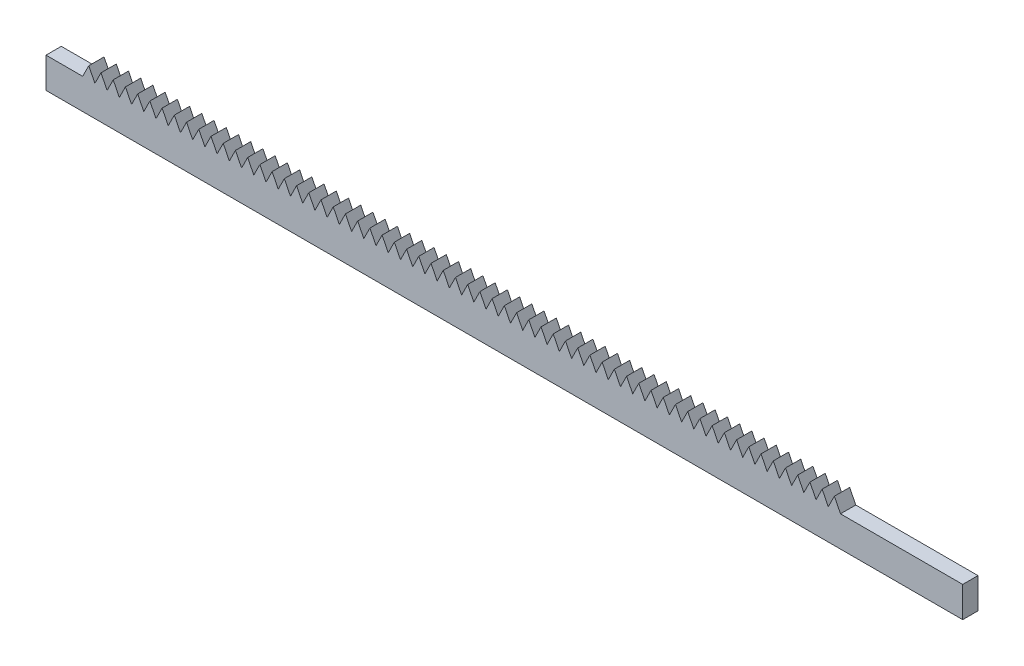
from build123d import *

# Parameters (mm, degrees)
SKETCH1_W           = 190.5
SKETCH1_H           = 6.35
BOSS_EXTRUDE1_DEPTH = 3.175
BOSS_EXTRUDE2_DEPTH = 3.175
LPATTERN1_COUNT     = 62
LPATTERN1_PITCH     = 2.54


with BuildPart() as part:
    # Sketch1 → Boss-Extrude1 (new body)
    with BuildSketch(Plane.XY):
        with Locations((95.25, 3.175)):
            Rectangle(SKETCH1_W, SKETCH1_H)
    extrude(amount=BOSS_EXTRUDE1_DEPTH)

    # Sketch2 → Boss-Extrude2 (add)
    with BuildSketch(Plane.XY.offset(3.175)):
        Polygon((165.1, 6.35), (163.83, 8.89), (162.56, 6.35), align=None)
    boss_extrude2 = extrude(amount=-BOSS_EXTRUDE2_DEPTH)

    # LPattern1: Boss-Extrude2 ×62
    with Locations(*[(-i * LPATTERN1_PITCH, 0, 0) for i in range(1, LPATTERN1_COUNT)]):
        add(boss_extrude2)


solid = part.part
